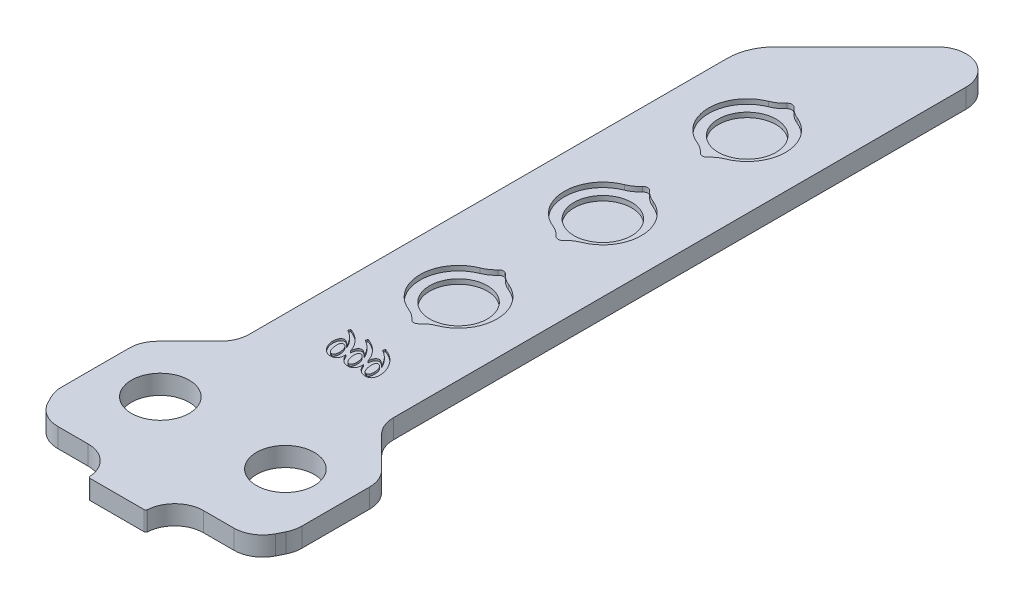
from build123d import *

# Parameters (mm, degrees)
BOSS_EXTRUDE1_DEPTH     = 1
SKETCH2_R               = 3
CUT_EXTRUDE2_DEPTH      = 2
CUT_EXTRUDE2_DEPTH_BACK = 2
SKETCH4_R               = 3
CUT_EXTRUDE4_DEPTH      = 2
CUT_EXTRUDE5_START      = 1
SKETCH4_3_R             = 4
SKETCH4_3_R_2           = 3
CUT_EXTRUDE5_DEPTH      = 0.5
FILLET7_R               = 0.5
LPATTERN2_COUNT         = 3
LPATTERN2_PITCH         = 15
FILLET7_OF_LPATTERN2_R  = 0.5
FILLET2_R               = 3
FILLET3_R               = 5
FILLET3_2_R             = 3
FILLET6_R               = 0.2
FILLET1_R               = 3
CUT_EXTRUDE8_START      = 0.8
CUT_EXTRUDE8_DEPTH      = 0.2


with BuildPart() as part:
    # Sketch1 → Boss-Extrude1 (new body, symmetric)
    with BuildSketch(Plane(origin=(0, 0, 0), x_dir=(1, 0, 0), z_dir=(0, 1, 0))):
        Polygon((-7.5, 73), (7.5, 88), (7.5, 20), (12.5, 15), (12.5, 6), (11, 3), (3, 3), (3, 0), (-3, 0), (-3, 3), (-11, 3), (-12.5, 6), (-12.5, 15), (-7.5, 20), align=None)
    extrude(amount=BOSS_EXTRUDE1_DEPTH, both=True)

    # Sketch2 → Cut-Extrude2 (cut, two sides)
    with BuildSketch(Plane(origin=(0, 0, 0), x_dir=(1, 0, 0), z_dir=(0, 1, 0))) as cut_extrude2_sk:
        with Locations((-6.5, 11)):
            Circle(SKETCH2_R)
        with Locations((6.5, 11)):
            Circle(SKETCH2_R)
    extrude(amount=CUT_EXTRUDE2_DEPTH, mode=Mode.SUBTRACT)
    extrude(cut_extrude2_sk.sketch, amount=-CUT_EXTRUDE2_DEPTH_BACK, mode=Mode.SUBTRACT)

    # Sketch4 → Cut-Extrude4 (cut, through all)
    with BuildSketch(Plane(origin=(0, 0, 0), x_dir=(1, 0, 0), z_dir=(0, 1, 0))):
        with Locations((0, 65.5)):
            Circle(SKETCH4_R)
    cut_extrude4 = extrude(amount=CUT_EXTRUDE4_DEPTH, mode=Mode.SUBTRACT)

    # Sketch4_3 → Cut-Extrude5 (cut)
    with BuildSketch(Plane(origin=(0, 0, 0), x_dir=(1, 0, 0), z_dir=(0, 1, 0)).offset(CUT_EXTRUDE5_START)):
        with BuildLine():
            ThreePointArc((-1.484614978, 69.214285714), (0, 69.5), (1.484614978, 69.214285714))
            ThreePointArc((1.484614978, 69.214285714), (0.634115199, 69.732213162), (0, 70.5))
            ThreePointArc((0, 70.5), (-0.634115199, 69.732213162), (-1.484614978, 69.214285714))
        make_face()
        with Locations((0, 65.5)):
            Circle(SKETCH4_3_R)
        with Locations((0, 65.5)):
            Circle(SKETCH4_3_R_2, mode=Mode.SUBTRACT)
        with BuildLine():
            ThreePointArc((0, 60.5), (0.634115199, 61.267786838), (1.484614978, 61.785714286))
            ThreePointArc((1.484614978, 61.785714286), (0, 61.5), (-1.484614978, 61.785714286))
            ThreePointArc((-1.484614978, 61.785714286), (-0.634115199, 61.267786838), (0, 60.5))
        make_face()
    cut_extrude5 = extrude(amount=-CUT_EXTRUDE5_DEPTH, mode=Mode.SUBTRACT)

    # Fillet7
    fillet7_edges = [part.edges().sort_by_distance(p)[0] for p in [
        (0, 0.75, -60.5),
        (0, 0.75, -70.5),
    ]]
    fillet(fillet7_edges, radius=FILLET7_R)

    # LPattern2: Cut-Extrude4, Cut-Extrude5 ×3
    with Locations(*[(0, 0, i * LPATTERN2_PITCH) for i in range(1, LPATTERN2_COUNT)]):
        add(cut_extrude4, mode=Mode.SUBTRACT)
        add(cut_extrude5, mode=Mode.SUBTRACT)

    # Fillet7 of LPattern2
    fillet7_of_lpattern2_edges = [part.edges().sort_by_distance(p)[0] for p in [
        (0, 0.75, -45.5),
        (0, 0.75, -55.5),
        (0, 0.75, -30.5),
        (0, 0.75, -40.5),
    ]]
    fillet(fillet7_of_lpattern2_edges, radius=FILLET7_OF_LPATTERN2_R)

    # Fillet2
    fillet2_edges = [part.edges().sort_by_distance(p)[0] for p in [
        (-7.5, 0, -20),
        (-12.5, 0, -15),
        (-12.5, 0, -6),
        (-11, 0, -3),
        (11, 0, -3),
        (12.5, 0, -6),
        (12.5, 0, -15),
        (7.5, 0, -20),
    ]]
    fillet(fillet2_edges, radius=FILLET2_R)

    # Fillet3
    fillet3_edges = [part.edges().sort_by_distance(p)[0] for p in [
        (-7.5, 0, -73),
    ]]
    fillet(fillet3_edges, radius=FILLET3_R)

    # Fillet3 2
    fillet3_2_edges = [part.edges().sort_by_distance(p)[0] for p in [
        (7.5, 0, -88),
    ]]
    fillet(fillet3_2_edges, radius=FILLET3_2_R)

    # Fillet6
    fillet6_edges = [part.edges().sort_by_distance(p)[0] for p in [
        (-3, 0, 0),
        (3, 0, 0),
    ]]
    fillet(fillet6_edges, radius=FILLET6_R)

    # Fillet1
    fillet1_edges = [part.edges().sort_by_distance(p)[0] for p in [
        (3, 0, -3),
        (-3, 0, -3),
    ]]
    fillet(fillet1_edges, radius=FILLET1_R)

    # Sketch10 → Cut-Extrude8 (cut)
    with BuildSketch(Plane(origin=(0, 0, 0), x_dir=(1, 0, 0), z_dir=(0, 1, 0)).offset(CUT_EXTRUDE8_START)):
        with BuildLine():
            add(Edge.make_bspline(
                [(0.875442505, 26.726559712), (0.947696868, 26.686036756), (1.091045705, 26.605641352), (1.290727218, 26.463216667), (1.47745556, 26.308739084), (1.649838397, 26.139336521), (1.807620386, 25.954940198), (1.951289532, 25.756110577), (2.081597312, 25.5432521), (2.155118179, 25.392584572), (2.192317505, 25.316351378)],
                knots=[0, 0, 0, 0, 0.000248367, 0.000492746, 0.000734549, 0.000974827, 0.00121684, 0.001461729, 0.001710084, 0.001964442, 0.001964442, 0.001964442, 0.001964442], degree=3))
            Line((2.192317505, 25.316351378), (2.181380005, 25.306872212))
            add(Edge.make_bspline(
                [(2.181380005, 25.306872212), (2.147563495, 25.341350427), (2.083164782, 25.407009261), (1.988189277, 25.497293231), (1.898150197, 25.572149766), (1.816007537, 25.635196077), (1.739619805, 25.683705972), (1.669691982, 25.718603731), (1.606116087, 25.742237607), (1.56466599, 25.745195398), (1.545546672, 25.746559712)],
                knots=[0, 0, 0, 0, 0.000144884, 0.000275911, 0.000392892, 0.000495996, 0.000586427, 0.000663712, 0.000730581, 0.000787834, 0.000787834, 0.000787834, 0.000787834], degree=3))
            add(Edge.make_bspline(
                [(1.545546672, 25.746559712), (1.529934894, 25.746083194), (1.498900417, 25.745135931), (1.45316338, 25.734858493), (1.408670927, 25.719894468), (1.365842723, 25.698017319), (1.323928778, 25.67110272), (1.28397832, 25.637104394), (1.245005789, 25.597466506), (1.208253106, 25.551730656), (1.173993568, 25.500944697), (1.143882863, 25.44504873), (1.118585425, 25.384393886), (1.097318646, 25.319365564), (1.081184815, 25.249579454), (1.070984217, 25.175113361), (1.062981359, 25.096070131), (1.062405549, 25.041721307), (1.062109172, 25.013747212)],
                knots=[0, 0, 0, 0, 4.6758e-05, 9.2949e-05, 0.00013999, 0.000187274, 0.000236825, 0.000289107, 0.000344278, 0.000403381, 0.000464861, 0.000527827, 0.000593509, 0.000661763, 0.000732867, 0.000808042, 0.000887129, 0.000971011, 0.000971011, 0.000971011, 0.000971011], degree=3))
            add(Edge.make_bspline(
                [(1.062109172, 25.013747212), (1.063245633, 24.966783894), (1.06549641, 24.873772389), (1.083059836, 24.735785838), (1.110234989, 24.600730978), (1.150194198, 24.468937928), (1.200454911, 24.340338188), (1.262289287, 24.214802266), (1.335251057, 24.092442211), (1.4182726, 23.974882174), (1.508317576, 23.865677458), (1.605372757, 23.770596752), (1.705189983, 23.68817654), (1.811286552, 23.622514541), (1.920988463, 23.569715527), (2.035903505, 23.533409863), (2.154953129, 23.510606083), (2.235964337, 23.507918034), (2.276900839, 23.506559712)],
                knots=[0, 0, 0, 0, 0.00014085, 0.000278955, 0.000416668, 0.000553697, 0.00069154, 0.000830459, 0.000973018, 0.001118476, 0.001261877, 0.001396968, 0.001525537, 0.001649358, 0.001770367, 0.001889817, 0.00200995, 0.002132667, 0.002132667, 0.002132667, 0.002132667], degree=3))
            add(Edge.make_bspline(
                [(2.276900839, 23.506559712), (2.306350118, 23.507190983), (2.363278167, 23.508411287), (2.445280402, 23.519687562), (2.521367801, 23.536999597), (2.591530568, 23.561583355), (2.655626799, 23.59377597), (2.713197779, 23.633659235), (2.764474612, 23.680711426), (2.809772686, 23.734282727), (2.849114637, 23.793421356), (2.882038587, 23.857231821), (2.912234658, 23.92395085), (2.934788917, 23.995349628), (2.953309266, 24.070328684), (2.966441221, 24.149046687), (2.973444902, 24.231710139), (2.974767826, 24.287971218), (2.975442505, 24.316663878)],
                knots=[0, 0, 0, 0, 8.8304e-05, 0.0001707, 0.000247816, 0.000322077, 0.000393166, 0.000462341, 0.0005315, 0.000601337, 0.000672321, 0.00074408, 0.000816562, 0.000891733, 0.000968309, 0.001048146, 0.001130863, 0.001216955, 0.001216955, 0.001216955, 0.001216955], degree=3))
            add(Edge.make_bspline(
                [(2.975442505, 24.316663878), (2.973902161, 24.380906039), (2.970816614, 24.509592934), (2.945597327, 24.702236314), (2.905724297, 24.89417717), (2.848944229, 25.085453756), (2.776543501, 25.2756741), (2.688577233, 25.465613706), (2.58378678, 25.654369109), (2.464197377, 25.841650309), (2.32992641, 26.02366552), (2.178260333, 26.19386241), (2.011654948, 26.35203814), (1.830572285, 26.499003857), (1.633770895, 26.633206346), (1.421981522, 26.755029794), (1.195571776, 26.865915967), (1.036579208, 26.928193387), (0.955650839, 26.959893045)],
                knots=[0, 0, 0, 0, 0.000192667, 0.000385942, 0.000581861, 0.000780283, 0.000983826, 0.001191966, 0.001407693, 0.001631, 0.00185821, 0.00208547, 0.00231395, 0.002546719, 0.002784361, 0.003027743, 0.003279175, 0.003539831, 0.003539831, 0.003539831, 0.003539831], degree=3))
            Line((0.955650839, 26.959893045), (0.875442505, 26.726559712))
        make_face()
        with BuildLine():
            add(Edge.make_bspline(
                [(2.121588339, 23.786559712), (2.103729068, 23.787519644), (2.068072066, 23.789436201), (2.016429167, 23.805687483), (1.966962233, 23.831115045), (1.920520997, 23.867141389), (1.876901865, 23.913785734), (1.835700016, 23.969902603), (1.797063701, 24.036319744), (1.748934597, 24.13758887), (1.698921418, 24.274473197), (1.653861748, 24.445716426), (1.627095286, 24.623042059), (1.623781555, 24.743137256), (1.622109172, 24.803747212)],
                knots=[0, 0, 0, 0, 5.3473e-05, 0.000106762, 0.000160898, 0.000219672, 0.000282078, 0.000351934, 0.000428092, 0.000512235, 0.000688041, 0.000864368, 0.001042768, 0.001224541, 0.001224541, 0.001224541, 0.001224541], degree=3))
            add(Edge.make_bspline(
                [(1.622109172, 24.803747212), (1.622569283, 24.840975483), (1.623432398, 24.910811468), (1.635812365, 25.008062166), (1.655026571, 25.090662543), (1.680960361, 25.15944752), (1.717318111, 25.212966305), (1.761641646, 25.252119127), (1.815086232, 25.276387114), (1.853731282, 25.278699752), (1.873671672, 25.279893045)],
                knots=[0, 0, 0, 0, 0.000111622, 0.00020939, 0.000293396, 0.000365702, 0.000428605, 0.00048547, 0.000541293, 0.000600804, 0.000600804, 0.000600804, 0.000600804], degree=3))
            add(Edge.make_bspline(
                [(1.873671672, 25.279893045), (1.891482406, 25.279004375), (1.926809294, 25.277241732), (1.979219221, 25.264360905), (2.029398712, 25.242115445), (2.078249153, 25.211689559), (2.124835224, 25.172701941), (2.169833613, 25.125061261), (2.213145167, 25.069060574), (2.254300064, 25.005356448), (2.291485577, 24.935853728), (2.325630767, 24.862947063), (2.353030141, 24.786134472), (2.375423433, 24.706380889), (2.394185457, 24.623994852), (2.40589494, 24.538095425), (2.414654547, 24.449310027), (2.41517737, 24.388874602), (2.415442505, 24.358226378)],
                knots=[0, 0, 0, 0, 5.3409e-05, 0.000105934, 0.000160796, 0.000217451, 0.000278042, 0.000342511, 0.000413689, 0.000490141, 0.00056975, 0.000650011, 0.000731434, 0.000814065, 0.000898453, 0.000984661, 0.00107398, 0.001165881, 0.001165881, 0.001165881, 0.001165881], degree=3))
            add(Edge.make_bspline(
                [(2.415442505, 24.358226378), (2.414786446, 24.313462444), (2.413559734, 24.229762128), (2.400032299, 24.11294041), (2.377544745, 24.013722575), (2.345785283, 23.931928093), (2.305268289, 23.866255695), (2.252308616, 23.820095746), (2.189912413, 23.790865355), (2.144754314, 23.788019584), (2.121588339, 23.786559712)],
                knots=[0, 0, 0, 0, 0.000134238, 0.000251, 0.000352165, 0.000438552, 0.000513384, 0.000581086, 0.000646683, 0.000715781, 0.000715781, 0.000715781, 0.000715781], degree=3))
        make_face(mode=Mode.SUBTRACT)
        with BuildLine():
            add(Edge.make_bspline(
                [(-0.930557495, 26.726559712), (-0.858303132, 26.686036756), (-0.714954295, 26.605641352), (-0.515272782, 26.463216667), (-0.32854444, 26.308739084), (-0.156161603, 26.139336521), (0.001620386, 25.954940198), (0.145289532, 25.756110577), (0.275597312, 25.5432521), (0.349118179, 25.392584572), (0.386317505, 25.316351378)],
                knots=[0, 0, 0, 0, 0.000248367, 0.000492746, 0.000734549, 0.000974827, 0.00121684, 0.001461729, 0.001710084, 0.001964442, 0.001964442, 0.001964442, 0.001964442], degree=3))
            Line((0.386317505, 25.316351378), (0.375380005, 25.306872212))
            add(Edge.make_bspline(
                [(0.375380005, 25.306872212), (0.341563495, 25.341350427), (0.277164782, 25.407009261), (0.182189277, 25.497293231), (0.092150197, 25.572149766), (0.010007537, 25.635196077), (-0.066380195, 25.683705972), (-0.136308018, 25.718603731), (-0.199883913, 25.742237607), (-0.24133401, 25.745195398), (-0.260453328, 25.746559712)],
                knots=[0, 0, 0, 0, 0.000144884, 0.000275911, 0.000392892, 0.000495996, 0.000586427, 0.000663712, 0.000730581, 0.000787834, 0.000787834, 0.000787834, 0.000787834], degree=3))
            add(Edge.make_bspline(
                [(-0.260453328, 25.746559712), (-0.276065106, 25.746083194), (-0.307099583, 25.745135931), (-0.35283662, 25.734858493), (-0.397329073, 25.719894468), (-0.440157277, 25.698017319), (-0.482071222, 25.67110272), (-0.52202168, 25.637104394), (-0.560994211, 25.597466506), (-0.597746894, 25.551730656), (-0.632006432, 25.500944697), (-0.662117137, 25.44504873), (-0.687414575, 25.384393886), (-0.708681354, 25.319365564), (-0.724815185, 25.249579454), (-0.735015783, 25.175113361), (-0.743018641, 25.096070131), (-0.743594451, 25.041721307), (-0.743890828, 25.013747212)],
                knots=[0, 0, 0, 0, 4.6758e-05, 9.2949e-05, 0.00013999, 0.000187274, 0.000236825, 0.000289107, 0.000344278, 0.000403381, 0.000464861, 0.000527827, 0.000593509, 0.000661763, 0.000732867, 0.000808042, 0.000887129, 0.000971011, 0.000971011, 0.000971011, 0.000971011], degree=3))
            add(Edge.make_bspline(
                [(-0.743890828, 25.013747212), (-0.742754367, 24.966783894), (-0.74050359, 24.873772389), (-0.722940164, 24.735785838), (-0.695765011, 24.600730978), (-0.655805802, 24.468937928), (-0.605545089, 24.340338188), (-0.543710713, 24.214802266), (-0.470748943, 24.092442211), (-0.3877274, 23.974882174), (-0.297682424, 23.865677458), (-0.200627243, 23.770596752), (-0.100810017, 23.68817654), (0.005286552, 23.622514541), (0.114988463, 23.569715527), (0.229903505, 23.533409863), (0.348953129, 23.510606083), (0.429964337, 23.507918034), (0.470900839, 23.506559712)],
                knots=[0, 0, 0, 0, 0.00014085, 0.000278955, 0.000416668, 0.000553697, 0.00069154, 0.000830459, 0.000973018, 0.001118476, 0.001261877, 0.001396968, 0.001525537, 0.001649358, 0.001770367, 0.001889817, 0.00200995, 0.002132667, 0.002132667, 0.002132667, 0.002132667], degree=3))
            add(Edge.make_bspline(
                [(0.470900839, 23.506559712), (0.500350118, 23.507190983), (0.557278167, 23.508411287), (0.639280402, 23.519687562), (0.715367801, 23.536999597), (0.785530568, 23.561583355), (0.849626799, 23.59377597), (0.907197779, 23.633659235), (0.958474612, 23.680711426), (1.003772686, 23.734282727), (1.043114637, 23.793421356), (1.076038587, 23.857231821), (1.106234658, 23.92395085), (1.128788917, 23.995349628), (1.147309266, 24.070328684), (1.160441221, 24.149046687), (1.167444902, 24.231710139), (1.168767826, 24.287971218), (1.169442505, 24.316663878)],
                knots=[0, 0, 0, 0, 8.8304e-05, 0.0001707, 0.000247816, 0.000322077, 0.000393166, 0.000462341, 0.0005315, 0.000601337, 0.000672321, 0.00074408, 0.000816562, 0.000891733, 0.000968309, 0.001048146, 0.001130863, 0.001216955, 0.001216955, 0.001216955, 0.001216955], degree=3))
            add(Edge.make_bspline(
                [(1.169442505, 24.316663878), (1.167902161, 24.380906039), (1.164816614, 24.509592934), (1.139597327, 24.702236314), (1.099724297, 24.89417717), (1.042944229, 25.085453756), (0.970543501, 25.2756741), (0.882577233, 25.465613706), (0.77778678, 25.654369109), (0.658197377, 25.841650309), (0.52392641, 26.02366552), (0.372260333, 26.19386241), (0.205654948, 26.35203814), (0.024572285, 26.499003857), (-0.172229105, 26.633206346), (-0.384018478, 26.755029794), (-0.610428224, 26.865915967), (-0.769420792, 26.928193387), (-0.850349161, 26.959893045)],
                knots=[0, 0, 0, 0, 0.000192667, 0.000385942, 0.000581861, 0.000780283, 0.000983826, 0.001191966, 0.001407693, 0.001631, 0.00185821, 0.00208547, 0.00231395, 0.002546719, 0.002784361, 0.003027743, 0.003279175, 0.003539831, 0.003539831, 0.003539831, 0.003539831], degree=3))
            Line((-0.850349161, 26.959893045), (-0.930557495, 26.726559712))
        make_face()
        with BuildLine():
            add(Edge.make_bspline(
                [(0.315588339, 23.786559712), (0.297729068, 23.787519644), (0.262072066, 23.789436201), (0.210429167, 23.805687483), (0.160962233, 23.831115045), (0.114520997, 23.867141389), (0.070901865, 23.913785734), (0.029700016, 23.969902603), (-0.008936299, 24.036319744), (-0.057065403, 24.13758887), (-0.107078582, 24.274473197), (-0.152138252, 24.445716426), (-0.178904714, 24.623042059), (-0.182218445, 24.743137256), (-0.183890828, 24.803747212)],
                knots=[0, 0, 0, 0, 5.3473e-05, 0.000106762, 0.000160898, 0.000219672, 0.000282078, 0.000351934, 0.000428092, 0.000512235, 0.000688041, 0.000864368, 0.001042768, 0.001224541, 0.001224541, 0.001224541, 0.001224541], degree=3))
            add(Edge.make_bspline(
                [(-0.183890828, 24.803747212), (-0.183430717, 24.840975483), (-0.182567602, 24.910811468), (-0.170187635, 25.008062166), (-0.150973429, 25.090662543), (-0.125039639, 25.15944752), (-0.088681889, 25.212966305), (-0.044358354, 25.252119127), (0.009086232, 25.276387114), (0.047731282, 25.278699752), (0.067671672, 25.279893045)],
                knots=[0, 0, 0, 0, 0.000111622, 0.00020939, 0.000293396, 0.000365702, 0.000428605, 0.00048547, 0.000541293, 0.000600804, 0.000600804, 0.000600804, 0.000600804], degree=3))
            add(Edge.make_bspline(
                [(0.067671672, 25.279893045), (0.085482406, 25.279004375), (0.120809294, 25.277241732), (0.173219221, 25.264360905), (0.223398712, 25.242115445), (0.272249153, 25.211689559), (0.318835224, 25.172701941), (0.363833613, 25.125061261), (0.407145167, 25.069060574), (0.448300064, 25.005356448), (0.485485577, 24.935853728), (0.519630767, 24.862947063), (0.547030141, 24.786134472), (0.569423433, 24.706380889), (0.588185457, 24.623994852), (0.59989494, 24.538095425), (0.608654547, 24.449310027), (0.60917737, 24.388874602), (0.609442505, 24.358226378)],
                knots=[0, 0, 0, 0, 5.3409e-05, 0.000105934, 0.000160796, 0.000217451, 0.000278042, 0.000342511, 0.000413689, 0.000490141, 0.00056975, 0.000650011, 0.000731434, 0.000814065, 0.000898453, 0.000984661, 0.00107398, 0.001165881, 0.001165881, 0.001165881, 0.001165881], degree=3))
            add(Edge.make_bspline(
                [(0.609442505, 24.358226378), (0.608786446, 24.313462444), (0.607559734, 24.229762128), (0.594032299, 24.11294041), (0.571544745, 24.013722575), (0.539785283, 23.931928093), (0.499268289, 23.866255695), (0.446308616, 23.820095746), (0.383912413, 23.790865355), (0.338754314, 23.788019584), (0.315588339, 23.786559712)],
                knots=[0, 0, 0, 0, 0.000134238, 0.000251, 0.000352165, 0.000438552, 0.000513384, 0.000581086, 0.000646683, 0.000715781, 0.000715781, 0.000715781, 0.000715781], degree=3))
        make_face(mode=Mode.SUBTRACT)
        with BuildLine():
            add(Edge.make_bspline(
                [(-2.736557495, 26.726559712), (-2.664303132, 26.686036756), (-2.520954295, 26.605641352), (-2.321272782, 26.463216667), (-2.13454444, 26.308739084), (-1.962161603, 26.139336521), (-1.804379614, 25.954940198), (-1.660710468, 25.756110577), (-1.530402688, 25.5432521), (-1.456881821, 25.392584572), (-1.419682495, 25.316351378)],
                knots=[0, 0, 0, 0, 0.000248367, 0.000492746, 0.000734549, 0.000974827, 0.00121684, 0.001461729, 0.001710084, 0.001964442, 0.001964442, 0.001964442, 0.001964442], degree=3))
            Line((-1.419682495, 25.316351378), (-1.430619995, 25.306872212))
            add(Edge.make_bspline(
                [(-1.430619995, 25.306872212), (-1.464436505, 25.341350427), (-1.528835218, 25.407009261), (-1.623810723, 25.497293231), (-1.713849803, 25.572149766), (-1.795992463, 25.635196077), (-1.872380195, 25.683705972), (-1.942308018, 25.718603731), (-2.005883913, 25.742237607), (-2.04733401, 25.745195398), (-2.066453328, 25.746559712)],
                knots=[0, 0, 0, 0, 0.000144884, 0.000275911, 0.000392892, 0.000495996, 0.000586427, 0.000663712, 0.000730581, 0.000787834, 0.000787834, 0.000787834, 0.000787834], degree=3))
            add(Edge.make_bspline(
                [(-2.066453328, 25.746559712), (-2.082065106, 25.746083194), (-2.113099583, 25.745135931), (-2.15883662, 25.734858493), (-2.203329073, 25.719894468), (-2.246157277, 25.698017319), (-2.288071222, 25.67110272), (-2.32802168, 25.637104394), (-2.366994211, 25.597466506), (-2.403746894, 25.551730656), (-2.438006432, 25.500944697), (-2.468117137, 25.44504873), (-2.493414575, 25.384393886), (-2.514681354, 25.319365564), (-2.530815185, 25.249579454), (-2.541015783, 25.175113361), (-2.549018641, 25.096070131), (-2.549594451, 25.041721307), (-2.549890828, 25.013747212)],
                knots=[0, 0, 0, 0, 4.6758e-05, 9.2949e-05, 0.00013999, 0.000187274, 0.000236825, 0.000289107, 0.000344278, 0.000403381, 0.000464861, 0.000527827, 0.000593509, 0.000661763, 0.000732867, 0.000808042, 0.000887129, 0.000971011, 0.000971011, 0.000971011, 0.000971011], degree=3))
            add(Edge.make_bspline(
                [(-2.549890828, 25.013747212), (-2.548754367, 24.966783894), (-2.54650359, 24.873772389), (-2.528940164, 24.735785838), (-2.501765011, 24.600730978), (-2.461805802, 24.468937928), (-2.411545089, 24.340338188), (-2.349710713, 24.214802266), (-2.276748943, 24.092442211), (-2.1937274, 23.974882174), (-2.103682424, 23.865677458), (-2.006627243, 23.770596752), (-1.906810017, 23.68817654), (-1.800713448, 23.622514541), (-1.691011537, 23.569715527), (-1.576096495, 23.533409863), (-1.457046871, 23.510606083), (-1.376035663, 23.507918034), (-1.335099161, 23.506559712)],
                knots=[0, 0, 0, 0, 0.00014085, 0.000278955, 0.000416668, 0.000553697, 0.00069154, 0.000830459, 0.000973018, 0.001118476, 0.001261877, 0.001396968, 0.001525537, 0.001649358, 0.001770367, 0.001889817, 0.00200995, 0.002132667, 0.002132667, 0.002132667, 0.002132667], degree=3))
            add(Edge.make_bspline(
                [(-1.335099161, 23.506559712), (-1.305649882, 23.507190983), (-1.248721833, 23.508411287), (-1.166719598, 23.519687562), (-1.090632199, 23.536999597), (-1.020469432, 23.561583355), (-0.956373201, 23.59377597), (-0.898802221, 23.633659235), (-0.847525388, 23.680711426), (-0.802227314, 23.734282727), (-0.762885363, 23.793421356), (-0.729961413, 23.857231821), (-0.699765342, 23.92395085), (-0.677211083, 23.995349628), (-0.658690734, 24.070328684), (-0.645558779, 24.149046687), (-0.638555098, 24.231710139), (-0.637232174, 24.287971218), (-0.636557495, 24.316663878)],
                knots=[0, 0, 0, 0, 8.8304e-05, 0.0001707, 0.000247816, 0.000322077, 0.000393166, 0.000462341, 0.0005315, 0.000601337, 0.000672321, 0.00074408, 0.000816562, 0.000891733, 0.000968309, 0.001048146, 0.001130863, 0.001216955, 0.001216955, 0.001216955, 0.001216955], degree=3))
            add(Edge.make_bspline(
                [(-0.636557495, 24.316663878), (-0.638097839, 24.380906039), (-0.641183386, 24.509592934), (-0.666402673, 24.702236314), (-0.706275703, 24.89417717), (-0.763055771, 25.085453756), (-0.835456499, 25.2756741), (-0.923422767, 25.465613706), (-1.02821322, 25.654369109), (-1.147802623, 25.841650309), (-1.28207359, 26.02366552), (-1.433739667, 26.19386241), (-1.600345052, 26.35203814), (-1.781427715, 26.499003857), (-1.978229105, 26.633206346), (-2.190018478, 26.755029794), (-2.416428224, 26.865915967), (-2.575420792, 26.928193387), (-2.656349161, 26.959893045)],
                knots=[0, 0, 0, 0, 0.000192667, 0.000385942, 0.000581861, 0.000780283, 0.000983826, 0.001191966, 0.001407693, 0.001631, 0.00185821, 0.00208547, 0.00231395, 0.002546719, 0.002784361, 0.003027743, 0.003279175, 0.003539831, 0.003539831, 0.003539831, 0.003539831], degree=3))
            Line((-2.656349161, 26.959893045), (-2.736557495, 26.726559712))
        make_face()
        with BuildLine():
            add(Edge.make_bspline(
                [(-1.490411661, 23.786559712), (-1.508270932, 23.787519644), (-1.543927934, 23.789436201), (-1.595570833, 23.805687483), (-1.645037767, 23.831115045), (-1.691479003, 23.867141389), (-1.735098135, 23.913785734), (-1.776299984, 23.969902603), (-1.814936299, 24.036319744), (-1.863065403, 24.13758887), (-1.913078582, 24.274473197), (-1.958138252, 24.445716426), (-1.984904714, 24.623042059), (-1.988218445, 24.743137256), (-1.989890828, 24.803747212)],
                knots=[0, 0, 0, 0, 5.3473e-05, 0.000106762, 0.000160898, 0.000219672, 0.000282078, 0.000351934, 0.000428092, 0.000512235, 0.000688041, 0.000864368, 0.001042768, 0.001224541, 0.001224541, 0.001224541, 0.001224541], degree=3))
            add(Edge.make_bspline(
                [(-1.989890828, 24.803747212), (-1.989430717, 24.840975483), (-1.988567602, 24.910811468), (-1.976187635, 25.008062166), (-1.956973429, 25.090662543), (-1.931039639, 25.15944752), (-1.894681889, 25.212966305), (-1.850358354, 25.252119127), (-1.796913768, 25.276387114), (-1.758268718, 25.278699752), (-1.738328328, 25.279893045)],
                knots=[0, 0, 0, 0, 0.000111622, 0.00020939, 0.000293396, 0.000365702, 0.000428605, 0.00048547, 0.000541293, 0.000600804, 0.000600804, 0.000600804, 0.000600804], degree=3))
            add(Edge.make_bspline(
                [(-1.738328328, 25.279893045), (-1.720517594, 25.279004375), (-1.685190706, 25.277241732), (-1.632780779, 25.264360905), (-1.582601288, 25.242115445), (-1.533750847, 25.211689559), (-1.487164776, 25.172701941), (-1.442166387, 25.125061261), (-1.398854833, 25.069060574), (-1.357699936, 25.005356448), (-1.320514423, 24.935853728), (-1.286369233, 24.862947063), (-1.258969859, 24.786134472), (-1.236576567, 24.706380889), (-1.217814543, 24.623994852), (-1.20610506, 24.538095425), (-1.197345453, 24.449310027), (-1.19682263, 24.388874602), (-1.196557495, 24.358226378)],
                knots=[0, 0, 0, 0, 5.3409e-05, 0.000105934, 0.000160796, 0.000217451, 0.000278042, 0.000342511, 0.000413689, 0.000490141, 0.00056975, 0.000650011, 0.000731434, 0.000814065, 0.000898453, 0.000984661, 0.00107398, 0.001165881, 0.001165881, 0.001165881, 0.001165881], degree=3))
            add(Edge.make_bspline(
                [(-1.196557495, 24.358226378), (-1.197213554, 24.313462444), (-1.198440266, 24.229762128), (-1.211967701, 24.11294041), (-1.234455255, 24.013722575), (-1.266214717, 23.931928093), (-1.306731711, 23.866255695), (-1.359691384, 23.820095746), (-1.422087587, 23.790865355), (-1.467245686, 23.788019584), (-1.490411661, 23.786559712)],
                knots=[0, 0, 0, 0, 0.000134238, 0.000251, 0.000352165, 0.000438552, 0.000513384, 0.000581086, 0.000646683, 0.000715781, 0.000715781, 0.000715781, 0.000715781], degree=3))
        make_face(mode=Mode.SUBTRACT)
    extrude(amount=CUT_EXTRUDE8_DEPTH, mode=Mode.SUBTRACT)


solid = part.part
